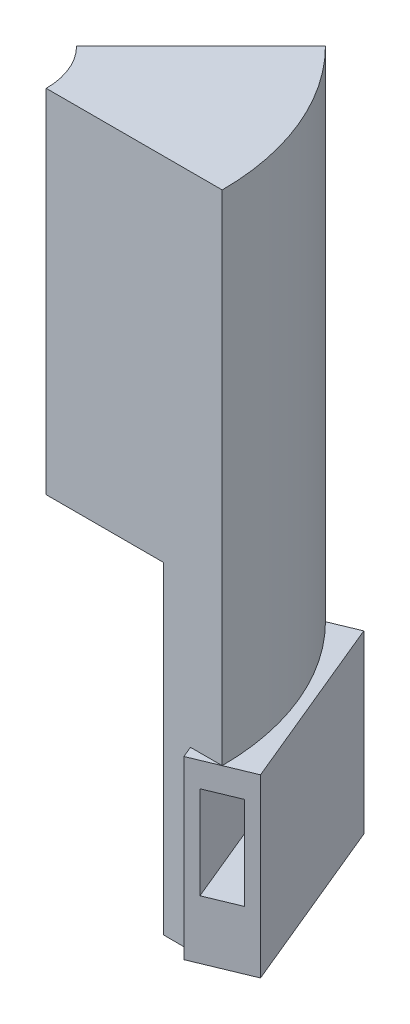
from build123d import *

# Parameters (mm, degrees)
REVOLVE1_ANGLE      = 45
SKETCH2_W           = 32.528091751
SKETCH2_H           = 30
BOSS_EXTRUDE1_DEPTH = 5
SKETCH3_W           = 5.8
SKETCH3_H           = 15.8
CUT_EXTRUDE1_DEPTH  = 43.413800206


with BuildPart() as part:
    # Sketch1 → Revolve1 (revolve)
    with BuildSketch(Plane.XY):
        Polygon((0, 0), (0, 60), (30, 60), (30, -55), (20, -55), (20, 0), align=None)
    revolve(axis=Axis((-12.5, 0, 0), (0, 1, 0)), revolution_arc=REVOLVE1_ANGLE)

    # Sketch2 → Boss-Extrude1 (add, symmetric)
    with BuildSketch(Plane(origin=(25.606601718, 0, -10.606601718), x_dir=(0.382683432, 0, 0.923879533), z_dir=(-0.923879533, 0, 0.382683432))):
        with Locations((-4.783542905, -40)):
            Rectangle(SKETCH2_W, SKETCH2_H)
    extrude(amount=BOSS_EXTRUDE1_DEPTH, both=True)

    # Sketch3 → Cut-Extrude1 (cut, through all)
    with BuildSketch(Plane(origin=(4.393398282, 0, 10.606601718), x_dir=(0.923879533, 0, -0.382683432), z_dir=(0.382683432, 0, 0.923879533))):
        with Locations((27.716385975, -37.1)):
            Rectangle(SKETCH3_W, SKETCH3_H)
    extrude(amount=-CUT_EXTRUDE1_DEPTH, mode=Mode.SUBTRACT)


solid = part.part
